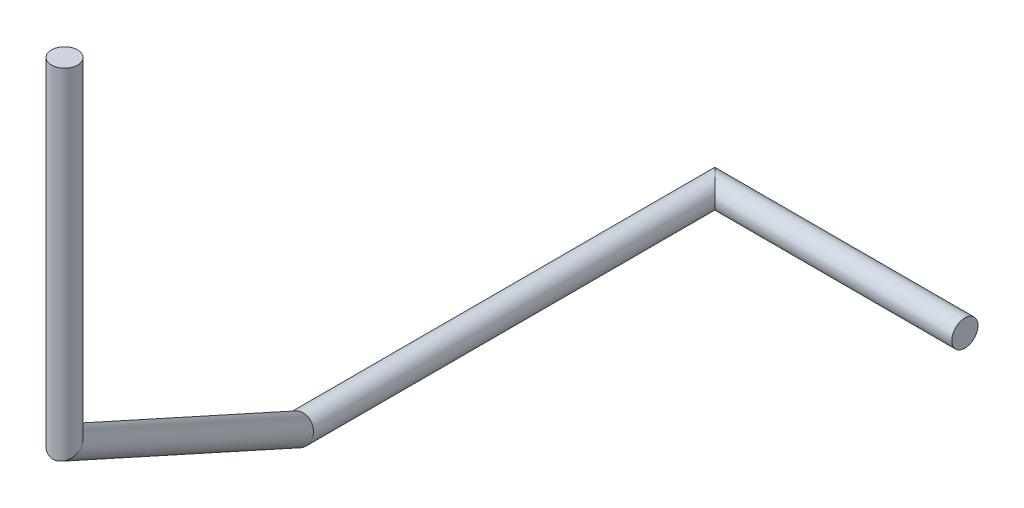
from build123d import *

# Parameters (mm, degrees)
SKETCH1_R = 1


with BuildPart() as part:
    # Sweep1: sweep along a curve in space
    with BuildLine() as sweep1_path:
        Line((0, 0, 0), (-19.05, 0, 0))
        Line((-19.05, 0, 0), (-19.05, 0, 31.75))
        Line((-19.05, 0, 31.75), (-10.825467117, 16.248060453, 57.758077406))
        Line((-10.825467117, 16.248060453, 57.758077406), (-10.825467117, 41.648060453, 57.758077406))
    # Sketch1 → Sweep1 (sweep)
    with BuildSketch(Plane(origin=(0, 0, 0), x_dir=(0, 0, -1), z_dir=(1, 0, 0))):
        Circle(SKETCH1_R)
    sweep(path=sweep1_path.line, transition=Transition.RIGHT)


solid = part.part
